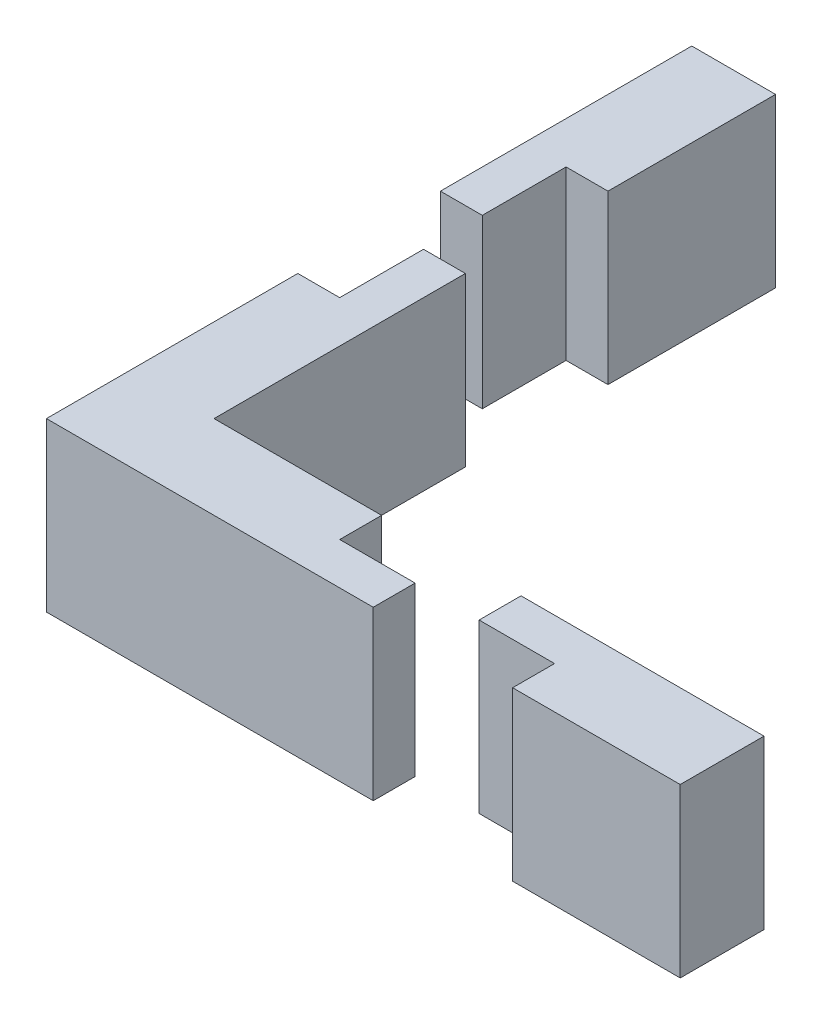
from build123d import *

# Parameters (mm, degrees)
SKETCH1_W           = 2.5
SKETCH1_H           = 5
SKETCH1_W_2         = 5
SKETCH1_H_2         = 15
SKETCH1_W_3         = 4.5
SKETCH1_H_3         = 2.5
BOSS_EXTRUDE2_DEPTH = 10


with BuildPart() as part:
    # Sketch1 → Boss-Extrude2 (new body)
    with BuildSketch(Plane(origin=(0, 0, 0), x_dir=(1, 0, 0), z_dir=(0, 1, 0))):
        Polygon((-2.5, 21.008471614), (0, 21.008471614), (2.5, 21.008471614), (2.5, 31.008471614), (-2.5, 31.008471614), align=None)
        with Locations((-1.25, 18.508471614)):
            Rectangle(SKETCH1_W, SKETCH1_H)
        with Locations((1.25, 10)):
            Rectangle(SKETCH1_W, SKETCH1_H)
        Rectangle(SKETCH1_W_2, SKETCH1_H_2)
        Polygon((2.5, -2.5), (2.5, -7.5), (12.5, -7.5), (12.5, -5), (12.5, -2.5), align=None)
        with Locations((14.75, -6.25)):
            Rectangle(SKETCH1_W_3, SKETCH1_H_3)
        with Locations((23.069397854, -3.75)):
            Rectangle(SKETCH1_W_3, SKETCH1_H_3)
        Polygon((25.319397854, -2.5), (25.319397854, -5), (25.319397854, -7.5), (35.319397854, -7.5), (35.319397854, -2.5), align=None)
    extrude(amount=BOSS_EXTRUDE2_DEPTH)


solid = part.part
